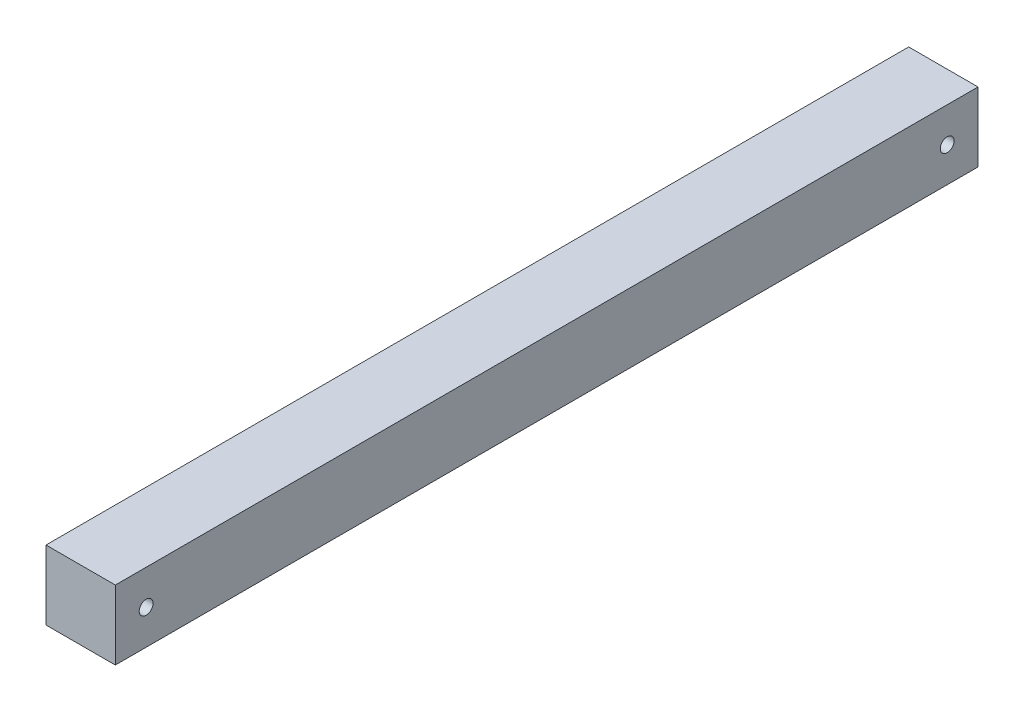
from build123d import *

# Parameters (mm, degrees)
ESQUISSE1_W             = 22.5
ESQUISSE1_H             = 22.5
BOSS_EXTRU_1_DEPTH      = 280
ENL_V_MAT_EXTRU_1_REACH = 24.5
ESQUISSE2_R             = 2.25


with BuildPart() as part:
    # Esquisse1 → Boss.-Extru.1 (new body)
    with BuildSketch(Plane.XY):
        with Locations((-16.740565009, 7.892670157)):
            Rectangle(ESQUISSE1_W, ESQUISSE1_H)
    extrude(amount=BOSS_EXTRU_1_DEPTH)

    # Esquisse2 → Enlèv. mat.-Extru.1 (cut, up to next)
    with BuildSketch(Plane(origin=(-5.490565009, 0, 0), x_dir=(0, 0, -1), z_dir=(1, 0, 0)), mode=Mode.PRIVATE) as enl_v_mat_extru_1_sk1:
        with Locations((-270, 7.892670157)):
            Circle(ESQUISSE2_R)
    enl_v_mat_extru_1_tool1 = extrude(enl_v_mat_extru_1_sk1.sketch, amount=-ENL_V_MAT_EXTRU_1_REACH, mode=Mode.PRIVATE) & part.part
    add(enl_v_mat_extru_1_tool1.solids().sort_by_distance((-5.490565, 7.89267, 270))[0], mode=Mode.SUBTRACT)
    # Esquisse2 → Enlèv. mat.-Extru.1 (cut, up to next)
    with BuildSketch(Plane(origin=(-5.490565009, 0, 0), x_dir=(0, 0, -1), z_dir=(1, 0, 0)), mode=Mode.PRIVATE) as enl_v_mat_extru_1_sk2:
        with Locations((-10, 7.892670157)):
            Circle(ESQUISSE2_R)
    enl_v_mat_extru_1_tool2 = extrude(enl_v_mat_extru_1_sk2.sketch, amount=-ENL_V_MAT_EXTRU_1_REACH, mode=Mode.PRIVATE) & part.part
    add(enl_v_mat_extru_1_tool2.solids().sort_by_distance((-5.490565, 7.89267, 10))[0], mode=Mode.SUBTRACT)


solid = part.part
